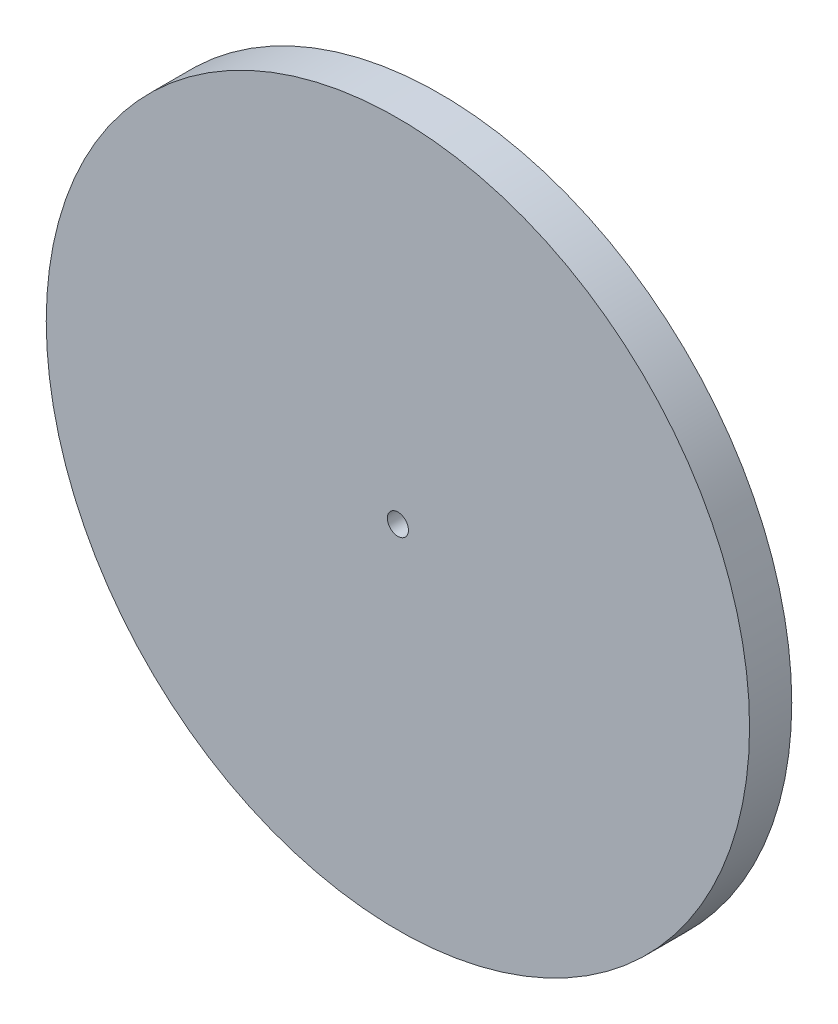
from build123d import *

# Parameters (mm, degrees)
SKETCH1_R           = 25
SKETCH1_R_2         = 0.75
BOSS_EXTRUDE1_DEPTH = 3


with BuildPart() as part:
    # Sketch1 → Boss-Extrude1 (new body)
    with BuildSketch(Plane.XY):
        Circle(SKETCH1_R)
        Circle(SKETCH1_R_2, mode=Mode.SUBTRACT)
    extrude(amount=BOSS_EXTRUDE1_DEPTH)


solid = part.part
